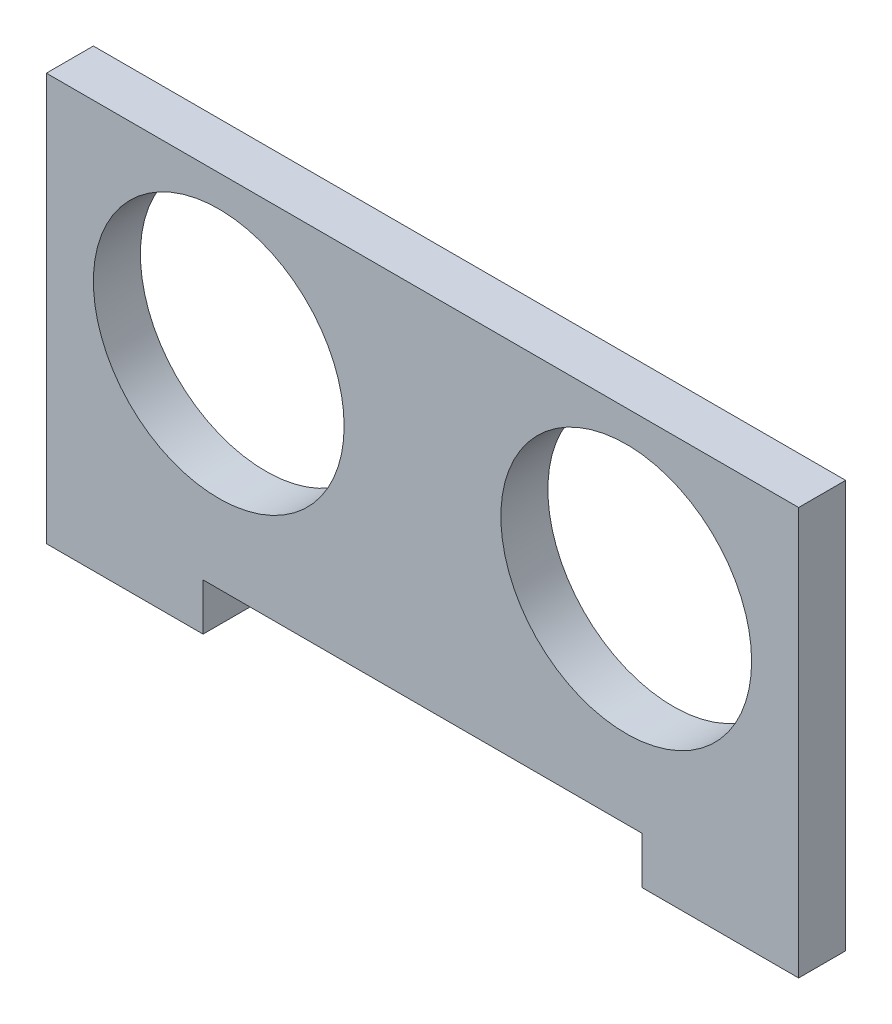
from build123d import *

# Parameters (mm, degrees)
MODEL_R                 = 8
SALIENTE_EXTRUIR1_DEPTH = 3


with BuildPart() as part:
    # Model → Saliente-Extruir1 (new body)
    with BuildSketch(Plane.XY):
        Polygon((42.2, 7.5), (14.2, 7.5), (14.2, 4.5), (4.2, 4.5), (4.2, 30.5), (52.2, 30.5), (52.2, 4.5), (42.2, 4.5), align=None)
        with Locations((41.2, 20.5)):
            Circle(MODEL_R, mode=Mode.SUBTRACT)
        with Locations((15.2, 20.5)):
            Circle(MODEL_R, mode=Mode.SUBTRACT)
    extrude(amount=SALIENTE_EXTRUIR1_DEPTH)


solid = part.part
